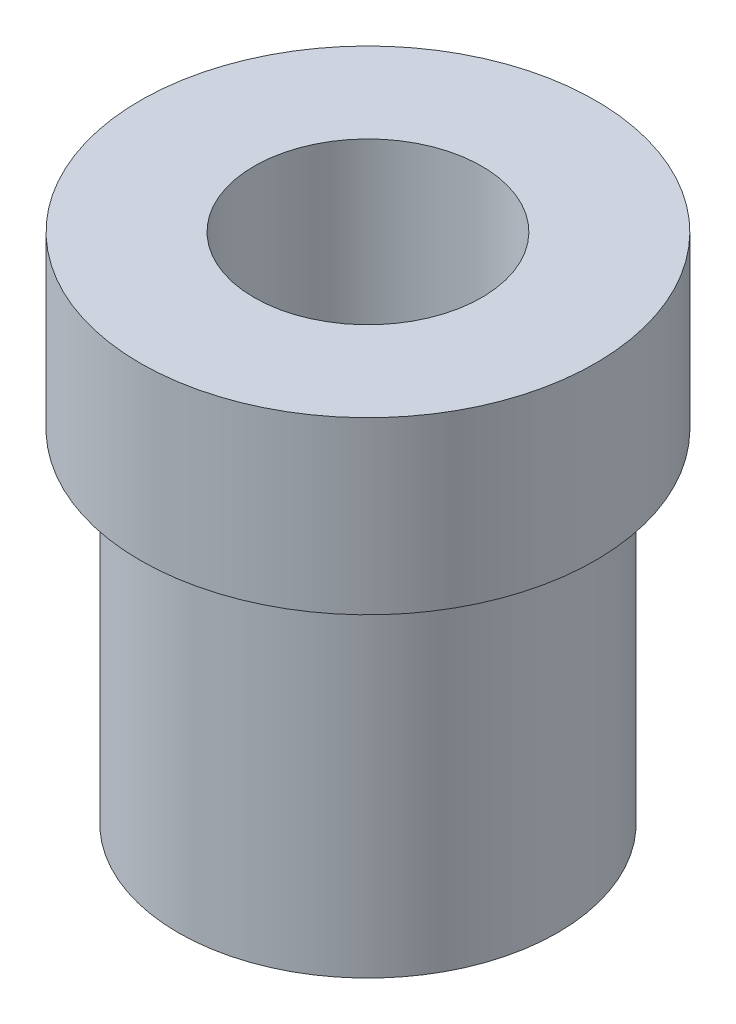
from build123d import *

# Parameters (mm, degrees)
SKETCH1_R               = 5
BOSS_EXTRUDE1_DEPTH     = 9
SKETCH2_R               = 6
BOSS_EXTRUDE2_DEPTH     = 4.5
SKETCH3_R               = 3
CUT_EXTRUDE1_DEPTH      = 1
CUT_EXTRUDE1_DEPTH_BACK = 14.5


with BuildPart() as part:
    # Sketch1 → Boss-Extrude1 (new body)
    with BuildSketch(Plane(origin=(0, 0, 0), x_dir=(1, 0, 0), z_dir=(0, 1, 0))):
        Circle(SKETCH1_R)
    extrude(amount=BOSS_EXTRUDE1_DEPTH)

    # Sketch2 → Boss-Extrude2 (add)
    with BuildSketch(Plane(origin=(0, 9, 0), x_dir=(1, 0, 0), z_dir=(0, 1, 0))):
        Circle(SKETCH2_R)
    extrude(amount=BOSS_EXTRUDE2_DEPTH)

    # Sketch3 → Cut-Extrude1 (cut, two sides)
    with BuildSketch(Plane(origin=(0, 13.5, 0), x_dir=(1, 0, 0), z_dir=(0, 1, 0))) as cut_extrude1_sk:
        Circle(SKETCH3_R)
    extrude(amount=CUT_EXTRUDE1_DEPTH, mode=Mode.SUBTRACT)
    extrude(cut_extrude1_sk.sketch, amount=-CUT_EXTRUDE1_DEPTH_BACK, mode=Mode.SUBTRACT)


solid = part.part
